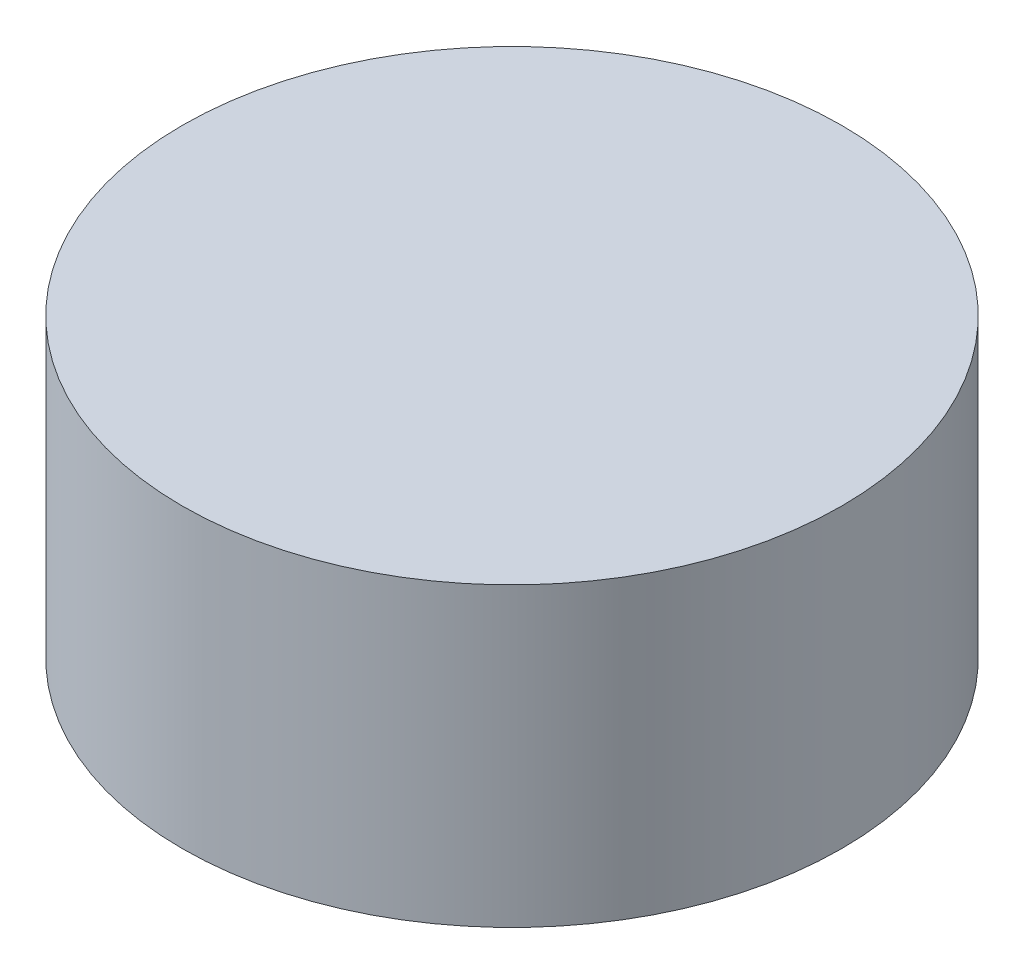
from build123d import *

# Parameters (mm, degrees)
SKETCH_1_R      = 5
EXTRUDE_1_DEPTH = 4.5


with BuildPart() as part:
    # ｽｹｯﾁ1 → ﾎﾞｽ - 押し出し1 (new body)
    with BuildSketch(Plane(origin=(0, 0, 0), x_dir=(1, 0, 0), z_dir=(0, 1, 0))):
        Circle(SKETCH_1_R)
    extrude(amount=EXTRUDE_1_DEPTH)


solid = part.part
